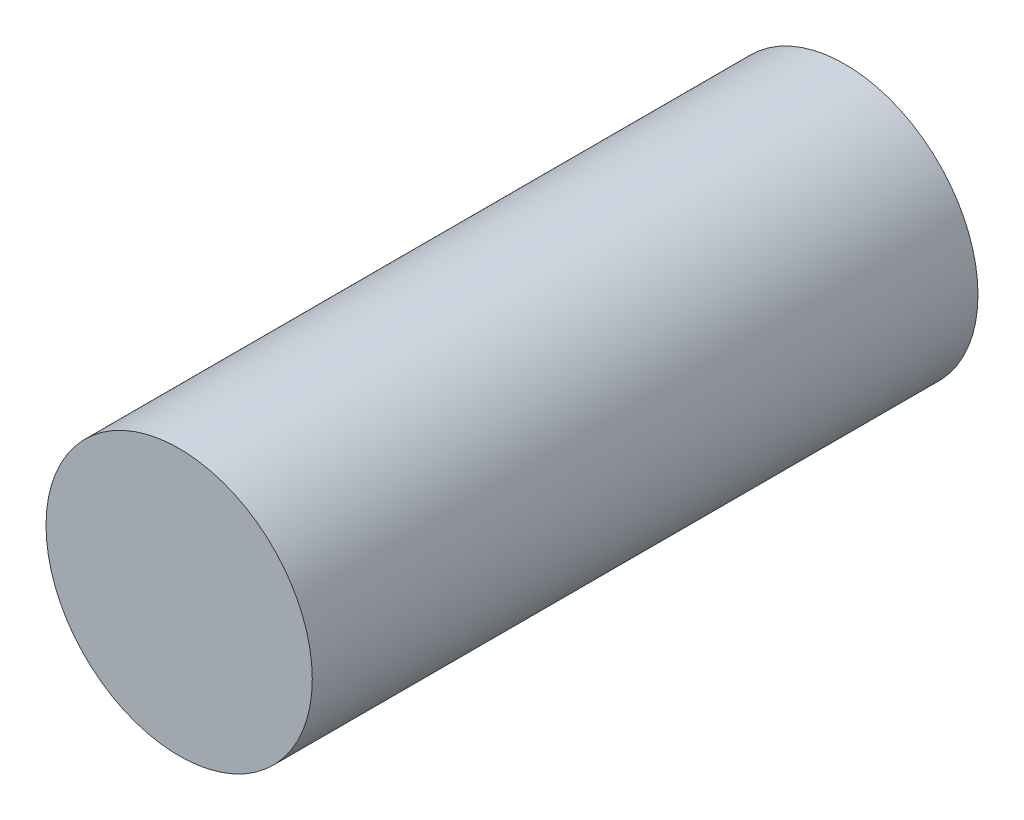
from build123d import *

# Parameters (mm, degrees)
SKETCH2_R           = 20
BOSS_EXTRUDE1_DEPTH = 100


with BuildPart() as part:
    # Sketch2 → Boss-Extrude1 (new body)
    with BuildSketch(Plane.XY):
        Circle(SKETCH2_R)
    extrude(amount=BOSS_EXTRUDE1_DEPTH)


solid = part.part
